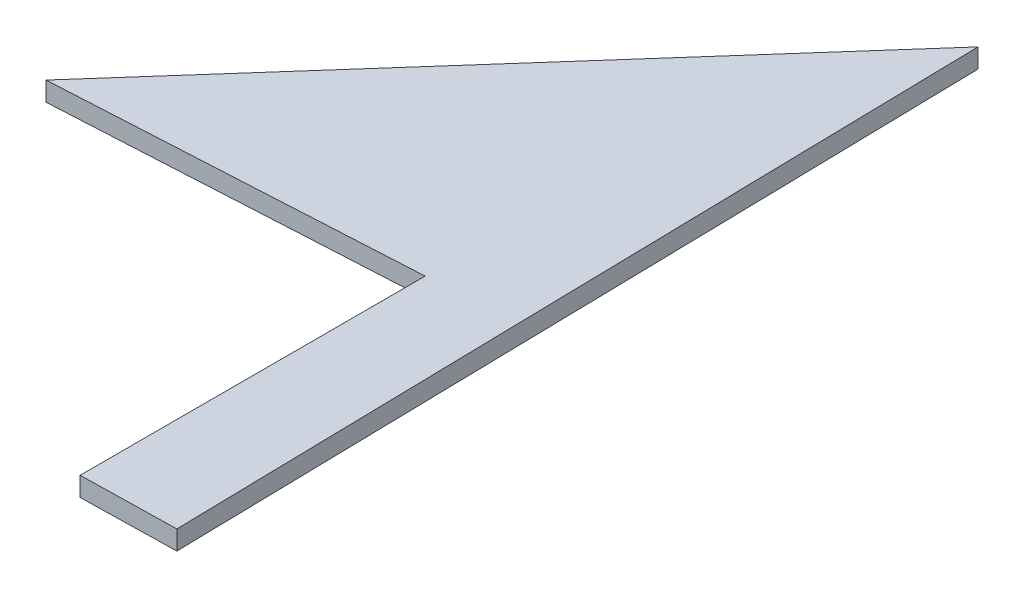
from build123d import *

# Parameters (mm, degrees)
BOSS_EXTRU_1_DEPTH = 2


with BuildPart() as part:
    # Esquisse1 → Boss.-Extru.1 (new body)
    with BuildSketch(Plane(origin=(0, 0, 0), x_dir=(1, 0, 0), z_dir=(0, 1, 0))):
        Polygon((37.382567155, 2.05724245), (37.382567155, -33.834277238), (47.245746725, -33.630979722), (45.49172957, 51.466893337), (0, 0), align=None)
    extrude(amount=BOSS_EXTRU_1_DEPTH)


solid = part.part
